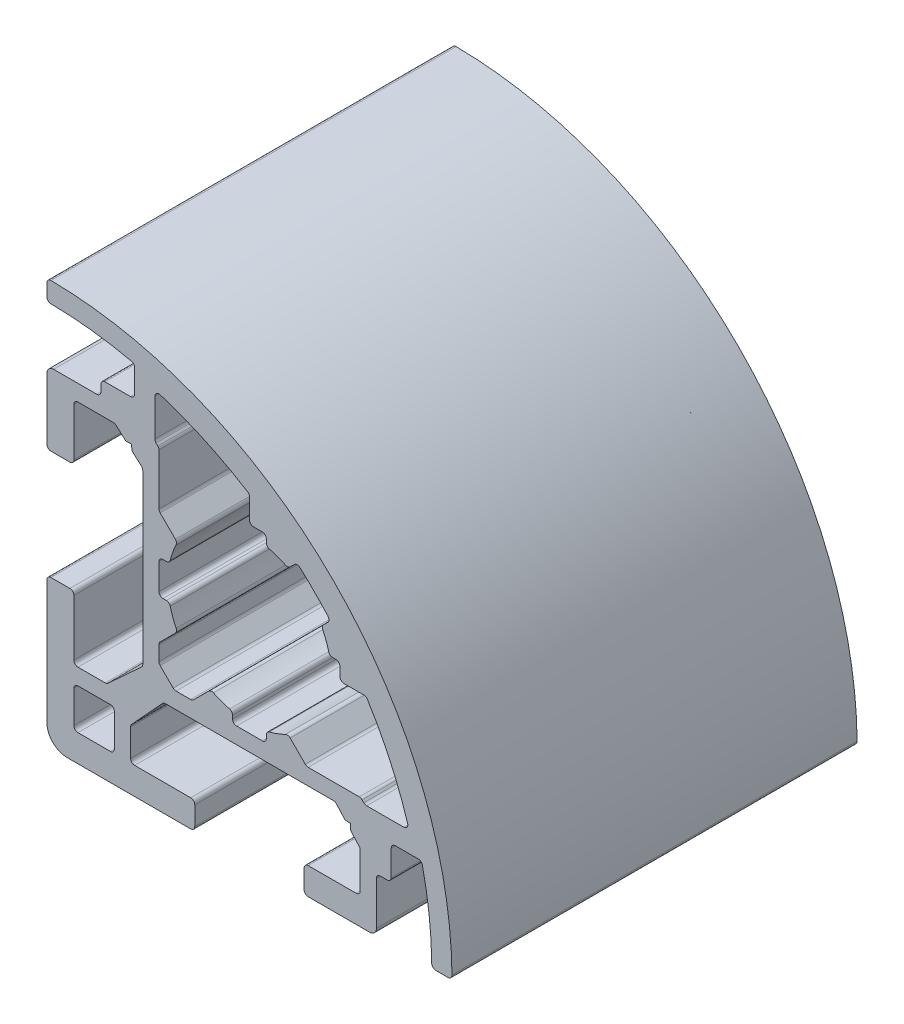
from build123d import *

# Parameters (mm, degrees)
RESSALTO_EXTRUS_O1_DEPTH = 30


with BuildPart() as part:
    # Esboço1 → Ressalto-extrusão1 (new body)
    with BuildSketch(Plane(origin=(0, 0, 0), x_dir=(-1, 0, 0), z_dir=(0, 0, -1))):
        with BuildLine():
            Line((7.988219541, 6.431982835), (8.704487641, 7.07202705))
            Line((8.704487641, 7.07202705), (8.728293149, 7.495764228))
            Line((8.728293149, 7.495764228), (9.151562381, 7.471985009))
            Line((9.151562381, 7.471985009), (9.867827891, 8.112011294))
            ThreePointArc((9.867827891, 8.112011294), (9.965155948, 8.177041539), (10.079961344, 8.199875818))
            Line((10.079961344, 8.199875818), (12.700062747, 8.199833365))
            ThreePointArc((12.700062747, 8.199833365), (12.912193499, 8.11196182), (13.000057886, 7.899828102))
            Line((13.000057886, 7.899828102), (12.999995614, 4.349871124))
            ThreePointArc((12.999995614, 4.349871124), (13.087860246, 4.137737161), (13.299991447, 4.049865862))
            Line((13.299991447, 4.049865862), (14.699990096, 4.049846419))
            ThreePointArc((14.699990096, 4.049846419), (14.912124824, 4.137712911), (14.999994262, 4.349846419))
            Line((14.999994262, 4.349846419), (14.999994262, 8.899908545))
            ThreePointArc((14.999994262, 8.899908545), (14.853547653, 9.253461936), (14.499994262, 9.399908545))
            Line((14.499994262, 9.399908545), (11.299984015, 9.399908545))
            ThreePointArc((11.299984015, 9.399908545), (11.087851981, 9.487776511), (10.999984015, 9.699908545))
            Line((10.999984015, 9.699908545), (10.999984015, 10.199939564))
            ThreePointArc((10.999984015, 10.199939564), (10.91211588, 10.412072007), (10.699983437, 10.499940142))
            Line((10.699983437, 10.499940142), (8.799996289, 10.499940142))
            ThreePointArc((8.799996289, 10.499940142), (8.587864255, 10.587808108), (8.499996289, 10.799940142))
            Line((8.499996289, 10.799940142), (8.499996289, 12.509984621))
            ThreePointArc((8.499996289, 12.509984621), (8.565702422, 12.697351597), (8.734038846, 12.802644177))
            ThreePointArc((8.734038846, 12.802644177), (11.700188414, 13.308311468), (14.703119279, 13.498440079))
            ThreePointArc((14.703119279, 13.498440079), (14.913228295, 13.587399521), (14.999994262, 13.798423803))
            Line((14.999994262, 13.798423803), (14.999994262, 14.698471418))
            ThreePointArc((14.999994262, 14.698471418), (14.911052198, 14.911672141), (14.696963943, 14.998456113))
            ThreePointArc((14.696963943, 14.998456113), (-6.213201777, 6.213195799), (-14.998473404, -14.696965168))
            ThreePointArc((-14.998473404, -14.696965168), (-14.91168949, -14.911053528), (-14.69848871, -14.99999565))
            Line((-14.69848871, -14.99999565), (-13.798441347, -14.99999565))
            ThreePointArc((-13.798441347, -14.99999565), (-13.587416943, -14.913229667), (-13.498457365, -14.70312058))
            ThreePointArc((-13.498457365, -14.70312058), (-13.308326814, -11.700187782), (-12.802657176, -8.734036533))
            ThreePointArc((-12.802657176, -8.734036533), (-12.69756035, -8.565856959), (-12.510499232, -8.499994604))
            Line((-12.510499232, -8.499994604), (-10.800466095, -8.49997976))
            ThreePointArc((-10.800466095, -8.49997976), (-10.588332377, -8.587846805), (-10.500463491, -8.79997976))
            Line((-10.500463491, -8.79997976), (-10.500463491, -10.699963204))
            ThreePointArc((-10.500463491, -10.699963204), (-10.412595525, -10.912095238), (-10.200463491, -10.999963204))
            Line((-10.200463491, -10.999963204), (-9.700412566, -10.999963204))
            ThreePointArc((-9.700412566, -10.999963204), (-9.488279549, -11.087832151), (-9.400412566, -11.299965981))
            Line((-9.400412566, -11.299965981), (-9.400442195, -14.49999102))
            ThreePointArc((-9.400442195, -14.49999102), (-9.253997222, -14.853547404), (-8.900442195, -14.99999565))
            Line((-8.900442195, -14.99999565), (-4.350452582, -14.99999565))
            ThreePointArc((-4.350452582, -14.99999565), (-4.138321038, -14.912128175), (-4.050452582, -14.699997039))
            Line((-4.050452582, -14.699997039), (-4.0504461, -13.299966156))
            ThreePointArc((-4.0504461, -13.299966156), (-4.138313069, -13.087833729), (-4.350444671, -12.999964767))
            Line((-4.350444671, -12.999964767), (-7.90045314, -12.999947852))
            ThreePointArc((-7.90045314, -12.999947852), (-8.112584733, -12.912078899), (-8.200451711, -12.699946488))
            Line((-8.200451711, -12.699946488), (-8.2004398, -10.079879081))
            ThreePointArc((-8.2004398, -10.079879081), (-8.177603139, -9.965074158), (-8.112570875, -9.867747451))
            Line((-8.112570875, -9.867747451), (-7.472516642, -9.151499458))
            Line((-7.472516642, -9.151499458), (-7.496307785, -8.728000464))
            Line((-7.496307785, -8.728000464), (-7.07269541, -8.704202951))
            Line((-7.07269541, -8.704202951), (-6.432641175, -7.987954957))
            ThreePointArc((-6.432641175, -7.987954957), (-6.33531386, -7.922923563), (-6.220508707, -7.900087947))
            Line((-6.220508707, -7.900087947), (6.219693645, -7.900145542))
            ThreePointArc((6.219693645, -7.900145542), (6.33449792, -7.922981945), (6.431824279, -7.988013496))
            Line((6.431824279, -7.988013496), (8.71172379, -10.467916072))
            ThreePointArc((8.71172379, -10.467916072), (8.776761952, -10.565245573), (8.799600807, -10.680055769))
            Line((8.799600807, -10.680055769), (8.79961016, -12.700073336))
            ThreePointArc((8.79961016, -12.700073336), (8.711742982, -12.912205971), (8.499611001, -13.000074725))
            Line((8.499611001, -13.000074725), (4.349602, -13.000086362))
            ThreePointArc((4.349602, -13.000086362), (4.137471001, -13.087954134), (4.049602841, -13.300084973))
            Line((4.049602841, -13.300084973), (4.04959636, -14.699994261))
            ThreePointArc((4.04959636, -14.699994261), (4.137463835, -14.912127193), (4.349596361, -14.99999565))
            Line((4.349596361, -14.99999565), (13.499994262, -14.99999565))
            ThreePointArc((13.499994262, -14.99999565), (14.560654434, -14.560655822), (14.999994262, -13.49999565))
            Line((14.999994262, -13.49999565), (14.999994262, -4.350307853))
            ThreePointArc((14.999994262, -4.350307853), (14.912126297, -4.138175819), (14.699994262, -4.050307853))
            Line((14.699994262, -4.050307853), (13.299941692, -4.050307853))
            ThreePointArc((13.299941692, -4.050307853), (13.087809804, -4.138175672), (12.999941692, -4.350307438))
            Line((12.999941692, -4.350307438), (12.999935957, -8.500264661))
            ThreePointArc((12.999935957, -8.500264661), (12.912067599, -8.712396673), (12.699935263, -8.800264247))
            Line((12.699935263, -8.800264247), (10.679833903, -8.800259571))
            ThreePointArc((10.679833903, -8.800259571), (10.565028929, -8.777423166), (10.467702076, -8.712391118))
            Line((10.467702076, -8.712391118), (7.987808147, -6.432485885))
            ThreePointArc((7.987808147, -6.432485885), (7.922994822, -6.335109576), (7.900348133, -6.220348782))
            Line((7.900348133, -6.220348782), (7.900348133, 6.219847358))
            ThreePointArc((7.900348133, 6.219847358), (7.923185205, 6.334654636), (7.988219541, 6.431982835))
        make_face()
        with BuildLine():
            Line((12.699997649, -12.999995366), (10.299997649, -12.999995366))
            ThreePointArc((10.299997649, -12.999995366), (10.087865615, -12.9121274), (9.999997649, -12.699995366))
            Line((9.999997649, -12.699995366), (9.999997649, -10.299995366))
            ThreePointArc((9.999997649, -10.299995366), (10.087865615, -10.087863332), (10.299997649, -9.999995366))
            Line((10.299997649, -9.999995366), (12.699997649, -9.999995366))
            ThreePointArc((12.699997649, -9.999995366), (12.912129683, -10.087863332), (12.999997649, -10.299995366))
            Line((12.999997649, -10.299995366), (12.999997649, -12.699995366))
            ThreePointArc((12.999997649, -12.699995366), (12.912129683, -12.9121274), (12.699997649, -12.999995366))
        make_face(mode=Mode.SUBTRACT)
        with BuildLine():
            Line((-0.949997542, 6.699991608), (-0.300006198, 6.699991608))
            ThreePointArc((-0.300006198, 6.699991608), (-0.087874164, 6.787859574), (-6.198e-06, 6.999991608))
            Line((-6.198e-06, 6.999991608), (-6.198e-06, 8.47764802))
            ThreePointArc((-6.198e-06, 8.47764802), (0.037542168, 8.622972279), (0.140788069, 8.731918614))
            ThreePointArc((0.140788069, 8.731918614), (3.280244614, 10.429262729), (6.61010457, 11.713473425))
            ThreePointArc((6.61010457, 11.713473425), (6.877524397, 11.669091748), (6.999996226, 11.427257614))
            Line((6.999996226, 11.427257614), (6.999996226, 8.679894243))
            ThreePointArc((6.999996226, 8.679894243), (6.977160088, 8.565089218), (6.912128268, 8.467762216))
            Line((6.912128268, 8.467762216), (6.787851146, 8.343485086))
            ThreePointArc((6.787851146, 8.343485086), (6.722819326, 8.246158084), (6.699983188, 8.131353059))
            Line((6.699983188, 8.131353059), (6.699983188, 4.349373523))
            ThreePointArc((6.699983188, 4.349373523), (6.677147048, 4.234568493), (6.612115222, 4.137241489))
            Line((6.612115222, 4.137241489), (5.487142739, 3.012269005))
            ThreePointArc((5.487142739, 3.012269005), (5.403317864, 2.849223708), (5.430017697, 2.667847035))
            ThreePointArc((5.430017697, 2.667847035), (5.679815237, 2.083794343), (5.866996881, 1.47676931))
            ThreePointArc((5.866996881, 1.47676931), (5.973488711, 1.313387662), (6.157922346, 1.249997541))
            Line((6.157922346, 1.249997541), (6.399983188, 1.249997541))
            ThreePointArc((6.399983188, 1.249997541), (6.612115222, 1.162129575), (6.699983188, 0.949997541))
            Line((6.699983188, 0.949997541), (6.699983188, -0.949997542))
            ThreePointArc((6.699983188, -0.949997542), (6.612115222, -1.162129576), (6.399983188, -1.249997542))
            Line((6.399983188, -1.249997542), (6.157922346, -1.249997542))
            ThreePointArc((6.157922346, -1.249997542), (5.973488711, -1.313387663), (5.866996881, -1.476769311))
            ThreePointArc((5.866996881, -1.476769311), (5.679815237, -2.083794344), (5.430017697, -2.667847036))
            ThreePointArc((5.430017697, -2.667847036), (5.403317864, -2.849223709), (5.487142739, -3.012269006))
            Line((5.487142739, -3.012269006), (6.612115222, -4.13724149))
            ThreePointArc((6.612115222, -4.13724149), (6.677147048, -4.234568494), (6.699983188, -4.349373524))
            Line((6.699983188, -4.349373524), (6.699983188, -5.439573887))
            ThreePointArc((6.699983188, -5.439573887), (6.677147048, -5.554378917), (6.612115222, -5.651705921))
            Line((6.612115222, -5.651705921), (5.651680826, -6.612140317))
            ThreePointArc((5.651680826, -6.612140317), (5.554353822, -6.677172143), (5.439548792, -6.700008283))
            Line((5.439548792, -6.700008283), (4.349398617, -6.700008283))
            ThreePointArc((4.349398617, -6.700008283), (4.234593588, -6.677172143), (4.137266583, -6.612140317))
            Line((4.137266583, -6.612140317), (3.012269005, -5.48714274))
            ThreePointArc((3.012269005, -5.48714274), (2.849223708, -5.403317864), (2.667847035, -5.430017698))
            ThreePointArc((2.667847035, -5.430017698), (2.083794343, -5.679815238), (1.47676931, -5.866996882))
            ThreePointArc((1.47676931, -5.866996882), (1.313387662, -5.973488713), (1.24999754, -6.157922347))
            Line((1.24999754, -6.157922347), (1.24999754, -6.400008283))
            ThreePointArc((1.24999754, -6.400008283), (1.162129575, -6.612140317), (0.94999754, -6.700008283))
            Line((0.94999754, -6.700008283), (-0.949997542, -6.700008283))
            ThreePointArc((-0.949997542, -6.700008283), (-1.162129576, -6.612140317), (-1.249997542, -6.400008283))
            Line((-1.249997542, -6.400008283), (-1.249997542, -6.157922347))
            ThreePointArc((-1.249997542, -6.157922347), (-1.313387663, -5.973488713), (-1.476769311, -5.866996882))
            ThreePointArc((-1.476769311, -5.866996882), (-2.083794344, -5.679815238), (-2.667847036, -5.430017698))
            ThreePointArc((-2.667847036, -5.430017698), (-2.849223709, -5.403317865), (-3.012269006, -5.48714274))
            Line((-3.012269006, -5.48714274), (-4.137266583, -6.612140317))
            ThreePointArc((-4.137266583, -6.612140317), (-4.234593588, -6.677172143), (-4.349398618, -6.700008283))
            Line((-4.349398618, -6.700008283), (-8.131377093, -6.700008283))
            ThreePointArc((-8.131377093, -6.700008283), (-8.246182127, -6.722844425), (-8.343509135, -6.787876256))
            Line((-8.343509135, -6.787876256), (-8.467778577, -6.912145707))
            ThreePointArc((-8.467778577, -6.912145707), (-8.565105584, -6.977177538), (-8.679910619, -7.00001368))
            Line((-8.679910619, -7.00001368), (-11.427275069, -7.00001368))
            ThreePointArc((-11.427275069, -7.00001368), (-11.669109203, -6.877541852), (-11.713490879, -6.610122025))
            ThreePointArc((-11.713490879, -6.610122025), (-10.429280184, -3.280262068), (-8.731936068, -0.140805524))
            ThreePointArc((-8.731936068, -0.140805524), (-8.622989733, -0.037559623), (-8.477665474, -1.1256e-05))
            Line((-8.477665474, -1.1256e-05), (-7.000004228, -1.1256e-05))
            ThreePointArc((-7.000004228, -1.1256e-05), (-6.787872194, 0.08785671), (-6.700004228, 0.299988744))
            Line((-6.700004228, 0.299988744), (-6.700004228, 0.94999754))
            ThreePointArc((-6.700004228, 0.94999754), (-6.612136263, 1.162129574), (-6.400004228, 1.24999754))
            Line((-6.400004228, 1.24999754), (-6.157922347, 1.24999754))
            ThreePointArc((-6.157922347, 1.24999754), (-5.973488713, 1.313387661), (-5.866996882, 1.476769309))
            ThreePointArc((-5.866996882, 1.476769309), (-5.679815238, 2.083794343), (-5.430017698, 2.667847035))
            ThreePointArc((-5.430017698, 2.667847035), (-5.403317865, 2.849223708), (-5.48714274, 3.012269005))
            Line((-5.48714274, 3.012269005), (-5.797444779, 3.322571045))
            ThreePointArc((-5.797444779, 3.322571045), (-5.885209902, 3.526848471), (-5.808258232, 3.735439996))
            ThreePointArc((-5.808258232, 3.735439996), (-4.798993375, 4.798993588), (-3.735438882, 5.808257496))
            ThreePointArc((-3.735438882, 5.808257496), (-3.526847423, 5.885208983), (-3.322570131, 5.797443864))
            Line((-3.322570131, 5.797443864), (-3.012269006, 5.487142739))
            ThreePointArc((-3.012269006, 5.487142739), (-2.849223709, 5.403317864), (-2.667847036, 5.430017697))
            ThreePointArc((-2.667847036, 5.430017697), (-2.083794344, 5.679815237), (-1.476769311, 5.866996881))
            ThreePointArc((-1.476769311, 5.866996881), (-1.313387663, 5.973488711), (-1.249997542, 6.157922346))
            Line((-1.249997542, 6.157922346), (-1.249997542, 6.399991608))
            ThreePointArc((-1.249997542, 6.399991608), (-1.162129576, 6.612123643), (-0.949997542, 6.699991608))
        make_face(mode=Mode.SUBTRACT)
    extrude(amount=-RESSALTO_EXTRUS_O1_DEPTH)


solid = part.part
